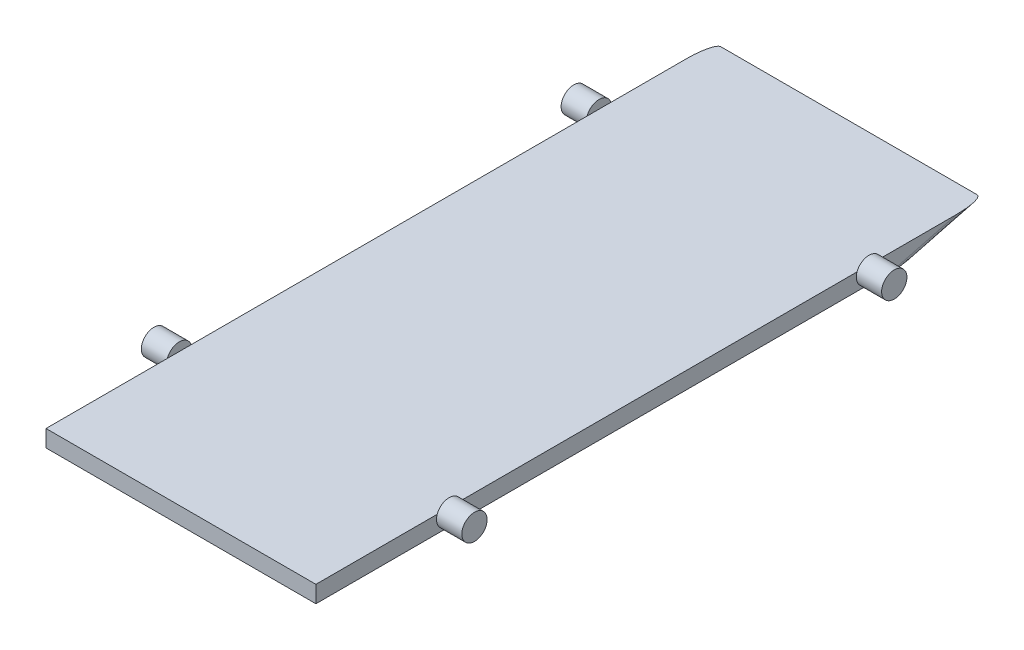
from build123d import *

# Parameters (mm, degrees)
SKETCH1_W           = 80
SKETCH1_H           = 198
BOSS_EXTRUDE1_DEPTH = 5
SKETCH2_R           = 3.75
BOSS_EXTRUDE2_DEPTH = 7.5
CUT_EXTRUDE1_DEPTH  = 88.5
FILLET2_R           = 2


with BuildPart() as part:
    # Sketch1 → Boss-Extrude1 (new body)
    with BuildSketch(Plane(origin=(0, 0, 0), x_dir=(1, 0, 0), z_dir=(0, 1, 0))):
        Rectangle(SKETCH1_W, SKETCH1_H)
    extrude(amount=BOSS_EXTRUDE1_DEPTH)

    # Sketch2 → Boss-Extrude2 (add)
    with BuildSketch(Plane.ZY.offset(40)):
        with Locations((-64.928905814, 3.75)):
            Circle(SKETCH2_R)
        with Locations((59.5, 3.75)):
            Circle(SKETCH2_R)
    boss_extrude2 = extrude(amount=BOSS_EXTRUDE2_DEPTH)

    # Mirror1: Boss-Extrude2 across plane
    add(boss_extrude2.mirror(Plane(origin=(0, 0, 0), x_dir=(0, 0, 1), z_dir=(1, 0, 0))))

    # Sketch3 → Cut-Extrude1 (cut, through all)
    with BuildSketch(Plane.ZY.offset(40)):
        Polygon((-99, 5), (-72.932513489, -1.759148434), (-103.799311702, -1.759148434), align=None)
    extrude(amount=-CUT_EXTRUDE1_DEPTH, mode=Mode.SUBTRACT)

    # Fillet2
    fillet2_edges = [part.edges().sort_by_distance(p)[0] for p in [
        (40, 2.5, -89.358442796),
        (-40, 2.5, -89.358442796),
    ]]
    fillet(fillet2_edges, radius=FILLET2_R)


solid = part.part
